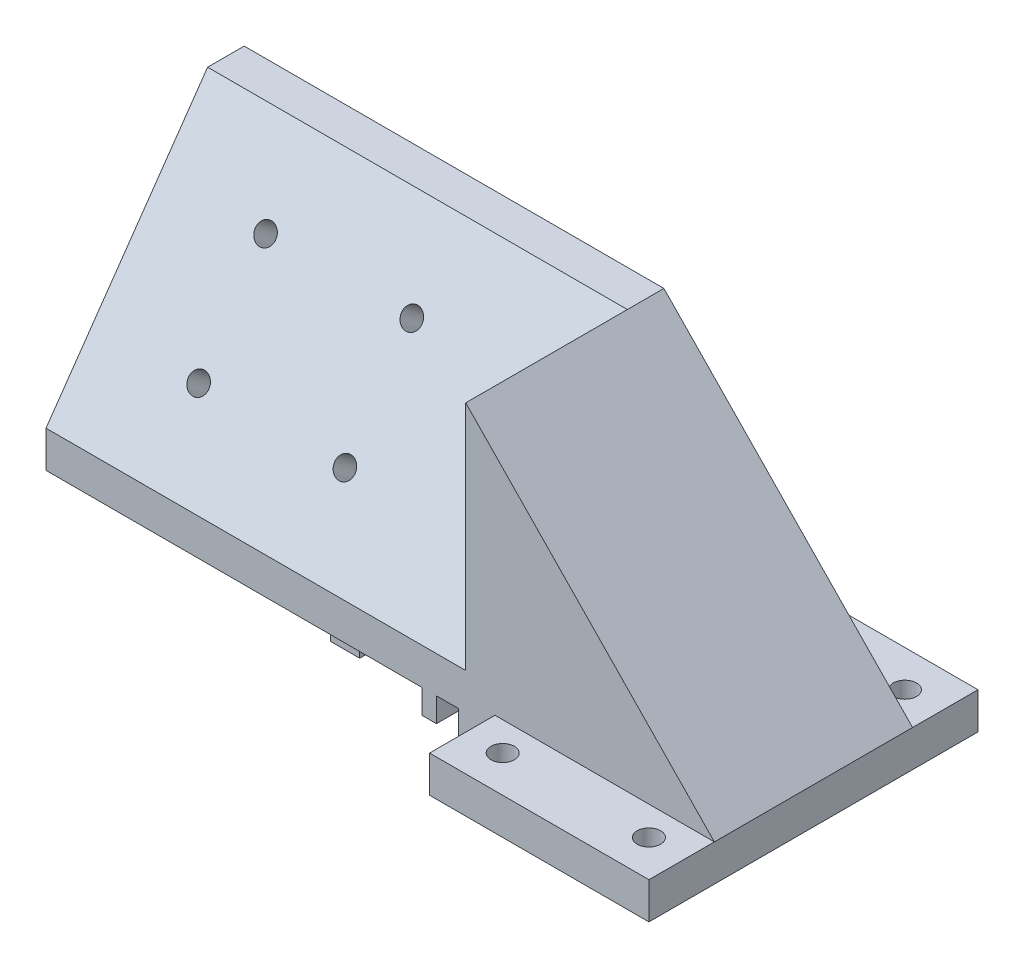
from build123d import *

# Parameters (mm, degrees)
SKETCH1_W                = 30
SKETCH1_H                = 45
SKETCH1_R                = 1.6
BOSS_EXTRUDE3_DEPTH      = 5
SKETCH2_W                = 64
SKETCH2_H                = 27.1
SKETCH2_W_2              = 30
BOSS_EXTRUDE4_DEPTH      = 35
BOSS_EXTRUDE4_DEPTH_BACK = 1.7
SKETCH3_W                = 4
SKETCH3_H                = 24.6
SKETCH3_W_2              = 5
SKETCH3_H_2              = 27.1
SKETCH3_W_3              = 2
BOSS_EXTRUDE5_DEPTH      = 3.3
CUT_EXTRUDE2_DEPTH       = 60
SKETCH6_R                = 1.4
CUT_EXTRUDE3_DEPTH       = 39
SKETCH7_W                = 27.1
SKETCH7_H                = 36.7
CUT_EXTRUDE4_DEPTH       = 2.6
CUT_EXTRUDE5_DEPTH       = 15
CUT_EXTRUDE5_DEPTH_BACK  = 15
CUT_EXTRUDE6_DEPTH       = 9.4
CUT_EXTRUDE7_DEPTH       = 37.05
FILLET1_R                = 2


with BuildPart() as part:
    # Sketch1 → Boss-Extrude3 (new body)
    with BuildSketch(Plane(origin=(0, 0, 0), x_dir=(1, 0, 0), z_dir=(0, 1, 0))):
        Rectangle(SKETCH1_W, SKETCH1_H)
        with Locations((-10, 17.5)):
            Circle(SKETCH1_R, mode=Mode.SUBTRACT)
        with Locations((10, 17.5)):
            Circle(SKETCH1_R, mode=Mode.SUBTRACT)
        with Locations((10, -17.5)):
            Circle(SKETCH1_R, mode=Mode.SUBTRACT)
        with Locations((-10, -17.5)):
            Circle(SKETCH1_R, mode=Mode.SUBTRACT)
    extrude(amount=BOSS_EXTRUDE3_DEPTH)

    # Sketch2 → Boss-Extrude4 (add, two sides)
    with BuildSketch(Plane(origin=(0, 5, 0), x_dir=(1, 0, 0), z_dir=(0, 1, 0))) as boss_extrude4_sk:
        with Locations((-47, 0)):
            Rectangle(SKETCH2_W, SKETCH2_H)
        Rectangle(SKETCH2_W_2, SKETCH2_H)
    extrude(amount=BOSS_EXTRUDE4_DEPTH)
    extrude(boss_extrude4_sk.sketch, amount=-BOSS_EXTRUDE4_DEPTH_BACK)

    # Sketch3 → Boss-Extrude5 (add)
    with BuildSketch(Plane.XZ.offset(-3.3)):
        with Locations((-38, -1.25)):
            Rectangle(SKETCH3_W, SKETCH3_H)
        with Locations((-17.5, 0)):
            Rectangle(SKETCH3_W_2, SKETCH3_H_2)
        with Locations((-24, 0)):
            Rectangle(SKETCH3_W_3, SKETCH3_H_2)
    extrude(amount=BOSS_EXTRUDE5_DEPTH)

    # Sketch5 → Cut-Extrude2 (cut)
    with BuildSketch(Plane.ZY.offset(79)):
        Polygon((-8.55, 40), (13.55, 8.3), (13.55, 40), align=None)
    extrude(amount=-CUT_EXTRUDE2_DEPTH, mode=Mode.SUBTRACT)

    # Sketch6 → Cut-Extrude3 (cut)
    with BuildSketch(Plane(origin=(0, 9.071537199, 13.012114445), x_dir=(1, 0, 0), z_dir=(0, 0.571898215, 0.820324589))):
        with Locations((-62, 26.38109329)):
            Circle(SKETCH6_R)
        with Locations((-42, 26.38109329)):
            Circle(SKETCH6_R)
        with Locations((-41.999995471, 10.38109329)):
            Circle(SKETCH6_R)
        with Locations((-61.999995471, 10.38109329)):
            Circle(SKETCH6_R)
    extrude(amount=-CUT_EXTRUDE3_DEPTH, mode=Mode.SUBTRACT)

    # Sketch7 → Cut-Extrude4 (cut)
    with BuildSketch(Plane.ZY.offset(79)):
        with Locations((0, 21.65)):
            Rectangle(SKETCH7_W, SKETCH7_H)
    extrude(amount=-CUT_EXTRUDE4_DEPTH, mode=Mode.SUBTRACT)

    # Sketch10 → Cut-Extrude5 (cut, two sides)
    with BuildSketch(Plane.ZY.offset(52)) as cut_extrude5_sk:
        Polygon((-13.55, 35), (-13.55, 3.3), (8.55, 3.3), (8.55, 6.729131215), (-11.159343853, 35), align=None)
    extrude(amount=CUT_EXTRUDE5_DEPTH, mode=Mode.SUBTRACT)
    extrude(cut_extrude5_sk.sketch, amount=-CUT_EXTRUDE5_DEPTH_BACK, mode=Mode.SUBTRACT)

    # Sketch11 → Cut-Extrude6 (cut)
    with BuildSketch(Plane.ZY.offset(76.4)):
        Polygon((-13.55, 35), (-13.55, 3.3), (8.55, 3.3), (8.55, 6.729131215), (-11.159343853, 35), align=None)
    extrude(amount=-CUT_EXTRUDE6_DEPTH, mode=Mode.SUBTRACT)

    # Sketch12 → Cut-Extrude7 (cut, through all)
    with BuildSketch(Plane.XY.offset(13.55)):
        Polygon((-19, 40), (15, 5), (15, 40), align=None)
    extrude(amount=-CUT_EXTRUDE7_DEPTH, mode=Mode.SUBTRACT)

    # Fillet1
    fillet1_edges = [part.edges().sort_by_distance(p)[0] for p in [
        (-37, 20.864565607, -1.304671927),
    ]]
    fillet(fillet1_edges, radius=FILLET1_R)


solid = part.part
